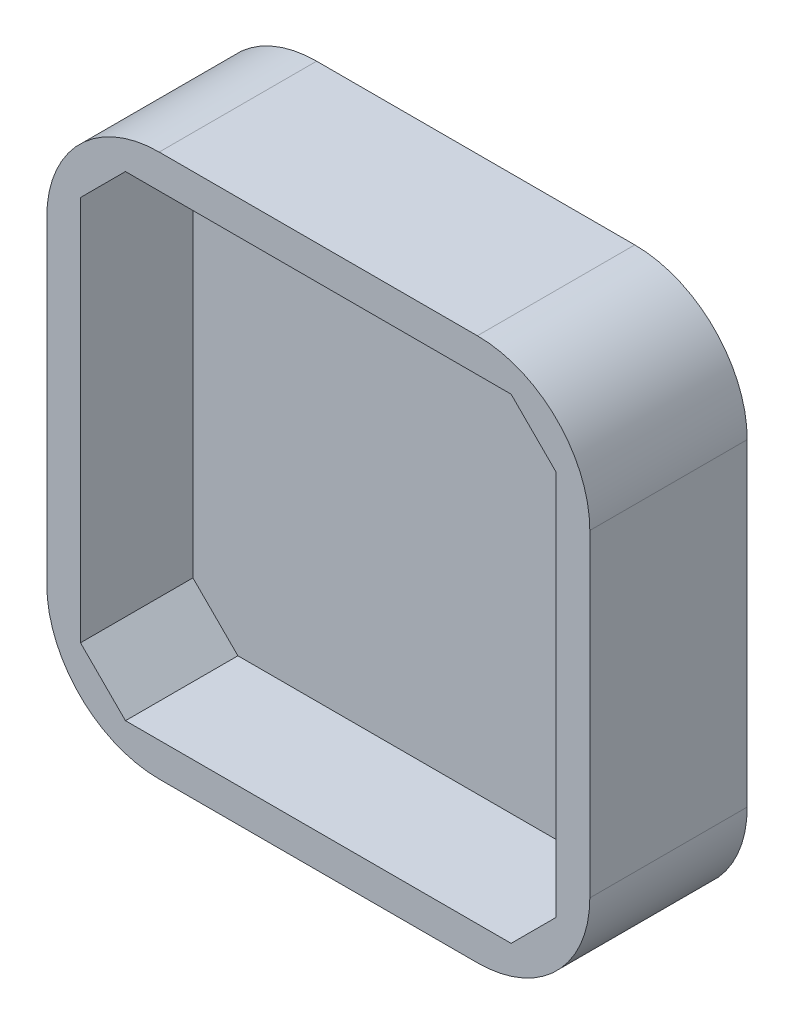
from build123d import *

# Parameters (mm, degrees)
SKETCH1_W           = 48.3
SKETCH1_H           = 48.3
BOSS_EXTRUDE1_DEPTH = 10
SKETCH1_3_W         = 48.3
SKETCH1_3_H         = 48.3
BOSS_EXTRUDE2_DEPTH = 4
SKETCH2_R           = 1.5
CUT_EXTRUDE1_DEPTH  = 3.5
FILLET1_R           = 10


with BuildPart() as part:
    # Sketch1 → Boss-Extrude1 (new body)
    with BuildSketch(Plane(origin=(0, 0, 7.613932461), x_dir=(-1, 0, 0), z_dir=(0, 0, -1))):
        with Locations((89.733633233, 8.444815184)):
            Rectangle(SKETCH1_W, SKETCH1_H)
        Polygon((110.883633233, 25.594815184), (110.883633233, -8.705184816), (106.883633233, -12.705184816), (72.583633233, -12.705184816), (68.583633233, -8.705184816), (68.583633233, 25.594815184), (72.583633233, 29.594815184), (106.883633233, 29.594815184), align=None, mode=Mode.SUBTRACT)
    extrude(amount=-BOSS_EXTRUDE1_DEPTH)

    # Sketch1_3 → Boss-Extrude2 (add)
    with BuildSketch(Plane(origin=(0, 0, 7.613932461), x_dir=(-1, 0, 0), z_dir=(0, 0, -1))):
        with Locations((89.733633233, 8.444815184)):
            Rectangle(SKETCH1_3_W, SKETCH1_3_H)
    extrude(amount=BOSS_EXTRUDE2_DEPTH)

    # Sketch2 → Cut-Extrude1 (cut)
    with BuildSketch(Plane(origin=(0, 0, 3.613932461), x_dir=(-1, 0, 0), z_dir=(0, 0, -1))):
        with Locations((105.233633233, 23.944815184)):
            Circle(SKETCH2_R)
        with Locations((105.233633233, -7.055184816)):
            Circle(SKETCH2_R)
        with Locations((74.233633233, -7.055184816)):
            Circle(SKETCH2_R)
        with Locations((74.233633233, 23.944815184)):
            Circle(SKETCH2_R)
    extrude(amount=-CUT_EXTRUDE1_DEPTH, mode=Mode.SUBTRACT)

    # Fillet1
    fillet1_edges = [part.edges().sort_by_distance(p)[0] for p in [
        (-113.883633233, 32.594815184, 10.613932461),
        (-113.883633233, -15.705184816, 10.613932461),
        (-65.583633233, -15.705184816, 10.613932461),
        (-65.583633233, 32.594815184, 10.613932461),
    ]]
    fillet(fillet1_edges, radius=FILLET1_R)


solid = part.part
